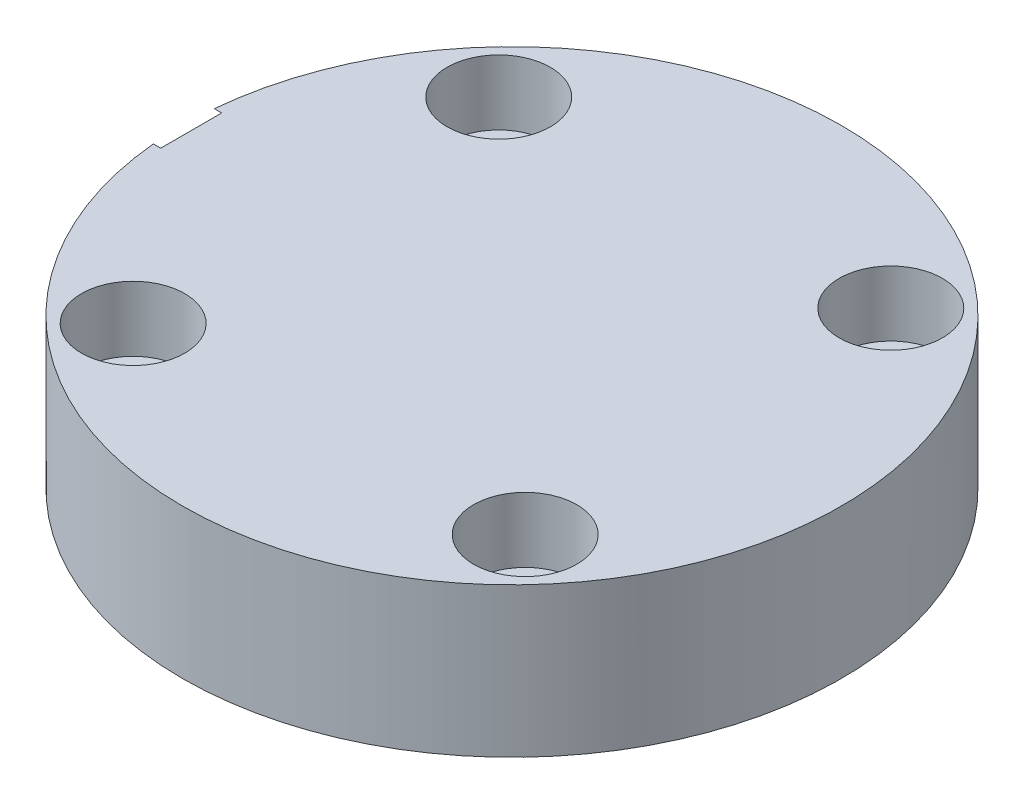
from build123d import *

# Parameters (mm, degrees)
SKETCH1_W         = 19.05
SKETCH1_H         = 8.636
HOLE1_D           = 3.9624
HOLE1_CBORE_D     = 5.969
HOLE1_CBORE_DEPTH = 3.7592
HOLE2_D           = 3.9624
HOLE2_CBORE_D     = 5.969
HOLE2_CBORE_DEPTH = 3.7592
HOLE3_D           = 3.9624
HOLE3_CBORE_D     = 5.969
HOLE3_CBORE_DEPTH = 3.7592
HOLE4_D           = 3.9624
HOLE4_CBORE_D     = 5.969
HOLE4_CBORE_DEPTH = 3.7592
HOLE5_D           = 20.6248
HOLE5_DEPTH       = 4.318
HOLE6_D           = 3.4544
HOLE6_DEPTH       = 4.318
HOLE7_D           = 3.4544
HOLE7_DEPTH       = 4.318
HOLE8_D           = 3.4544
HOLE8_DEPTH       = 4.318
HOLE9_D           = 3.4544
HOLE9_DEPTH       = 4.318


with BuildPart() as part:
    # Sketch1 → Revolve1 (revolve)
    with BuildSketch(Plane.XY):
        with Locations((9.525, 4.318)):
            Rectangle(SKETCH1_W, SKETCH1_H)
    revolve(axis=Axis((0, 0, 0), (0, 1, 0)))

    # Sketch2 → Cut-Revolve1 (revolve, cut)
    with BuildSketch(Plane.XY):
        Polygon((-19.05, 5.08), (-19.05, 9.04875), (-18.542, 9.04875), (-18.542, 7.493), (-18.11274, 7.06374), (-7.874, 7.06374), (-6.728687177, 5.08), align=None)
    revolve(axis=Axis((-6.728687177, 5.08, 0), (-1, 0, 0)), mode=Mode.SUBTRACT)

    # Hole1 (through all)
    with Locations(Plane(origin=(0, 8.636, 0), x_dir=(1, 0, 0), z_dir=(0, 1, 0))):
        with Locations((-10.566882591, -11.331594253)):
            CounterBoreHole(HOLE1_D / 2, HOLE1_CBORE_D / 2, HOLE1_CBORE_DEPTH)

    # Hole2 (through all)
    with Locations(Plane(origin=(0, 8.636, 0), x_dir=(1, 0, 0), z_dir=(0, 1, 0))):
        with Locations((11.331594253, -10.566882591)):
            CounterBoreHole(HOLE2_D / 2, HOLE2_CBORE_D / 2, HOLE2_CBORE_DEPTH)

    # Hole3 (through all)
    with Locations(Plane(origin=(0, 8.636, 0), x_dir=(1, 0, 0), z_dir=(0, 1, 0))):
        with Locations((10.566882591, 11.331594253)):
            CounterBoreHole(HOLE3_D / 2, HOLE3_CBORE_D / 2, HOLE3_CBORE_DEPTH)

    # Hole4 (through all)
    with Locations(Plane(origin=(0, 8.636, 0), x_dir=(1, 0, 0), z_dir=(0, 1, 0))):
        with Locations((-11.331594253, 10.566882591)):
            CounterBoreHole(HOLE4_D / 2, HOLE4_CBORE_D / 2, HOLE4_CBORE_DEPTH)

    # Hole5
    with Locations(Plane(origin=(0, 0, 0), x_dir=(-1, 0, 0), z_dir=(0, -1, 0))):
        with Locations((0, 0)):
            Hole(HOLE5_D / 2, depth=HOLE5_DEPTH)

    # Hole6
    with Locations(Plane(origin=(0, 0, 0), x_dir=(-1, 0, 0), z_dir=(0, -1, 0))):
        with Locations((14.930490242, -4.140591399)):
            Hole(HOLE6_D / 2, depth=HOLE6_DEPTH)

    # Hole7
    with Locations(Plane(origin=(0, 0, 0), x_dir=(-1, 0, 0), z_dir=(0, -1, 0))):
        with Locations((-4.140591399, -14.930490242)):
            Hole(HOLE7_D / 2, depth=HOLE7_DEPTH)

    # Hole8
    with Locations(Plane(origin=(0, 0, 0), x_dir=(-1, 0, 0), z_dir=(0, -1, 0))):
        with Locations((-14.930490242, 4.140591399)):
            Hole(HOLE8_D / 2, depth=HOLE8_DEPTH)

    # Hole9
    with Locations(Plane(origin=(0, 0, 0), x_dir=(-1, 0, 0), z_dir=(0, -1, 0))):
        with Locations((4.140591399, 14.930490242)):
            Hole(HOLE9_D / 2, depth=HOLE9_DEPTH)


solid = part.part
